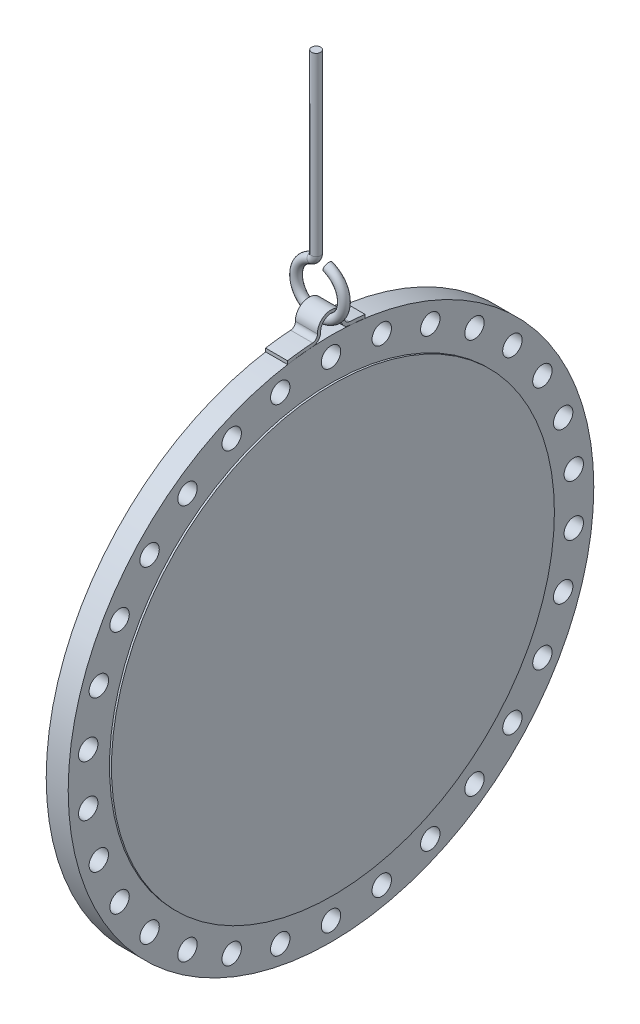
from build123d import *

# Parameters (mm, degrees)
CUT_EXTRUDE1_START  = -37
SKETCH2_R           = 15
CUT_EXTRUDE1_DEPTH  = 34
BOSS_EXTRUDE1_DEPTH = 34
SKETCH5_R           = 7


with BuildPart() as part:
    # Sketch1 → Revolve1 (revolve)
    with BuildSketch(Plane.XY):
        Polygon((0, 0), (-37, 0), (-37, 406.4), (-3, 406.4), (-3, 342.5), (0, 342.5), align=None)
    revolve(axis=Axis((0, 0, 0), (-1, 0, 0)))

    # Sketch2 → Cut-Extrude1 (cut)
    with BuildSketch(Plane(origin=(0, 0, 0), x_dir=(0, 0, -1), z_dir=(1, 0, 0)).offset(CUT_EXTRUDE1_START)):
        with Locations((0, 377.5)):
            Circle(SKETCH2_R)
        with Locations((78.486663284, 369.250719277)):
            Circle(SKETCH2_R)
        with Locations((153.543082761, 344.86341026)):
            Circle(SKETCH2_R)
        with Locations((221.88893274, 305.403915377)):
            Circle(SKETCH2_R)
        with Locations((280.537171618, 252.5968039)):
            Circle(SKETCH2_R)
        with Locations((326.924589929, 188.75)):
            Circle(SKETCH2_R)
        with Locations((359.023834901, 116.653915377)):
            Circle(SKETCH2_R)
        with Locations((375.432015502, 39.459494884)):
            Circle(SKETCH2_R)
        with Locations((375.432015502, -39.459494884)):
            Circle(SKETCH2_R)
        with Locations((359.023834901, -116.653915377)):
            Circle(SKETCH2_R)
        with Locations((326.924589929, -188.75)):
            Circle(SKETCH2_R)
        with Locations((280.537171618, -252.5968039)):
            Circle(SKETCH2_R)
        with Locations((221.88893274, -305.403915377)):
            Circle(SKETCH2_R)
        with Locations((153.543082761, -344.86341026)):
            Circle(SKETCH2_R)
        with Locations((78.486663284, -369.250719277)):
            Circle(SKETCH2_R)
        with Locations((0, -377.5)):
            Circle(SKETCH2_R)
        with Locations((-78.486663284, -369.250719277)):
            Circle(SKETCH2_R)
        with Locations((-153.543082761, -344.86341026)):
            Circle(SKETCH2_R)
        with Locations((-221.88893274, -305.403915377)):
            Circle(SKETCH2_R)
        with Locations((-280.537171618, -252.5968039)):
            Circle(SKETCH2_R)
        with Locations((-326.924589929, -188.75)):
            Circle(SKETCH2_R)
        with Locations((-359.023834901, -116.653915377)):
            Circle(SKETCH2_R)
        with Locations((-375.432015502, -39.459494884)):
            Circle(SKETCH2_R)
        with Locations((-375.432015502, 39.459494884)):
            Circle(SKETCH2_R)
        with Locations((-359.023834901, 116.653915377)):
            Circle(SKETCH2_R)
        with Locations((-326.924589929, 188.75)):
            Circle(SKETCH2_R)
        with Locations((-280.537171618, 252.5968039)):
            Circle(SKETCH2_R)
        with Locations((-221.88893274, 305.403915377)):
            Circle(SKETCH2_R)
        with Locations((-153.543082761, 344.86341026)):
            Circle(SKETCH2_R)
        with Locations((-78.486663284, 369.250719277)):
            Circle(SKETCH2_R)
    extrude(amount=CUT_EXTRUDE1_DEPTH, mode=Mode.SUBTRACT)


with BuildPart() as body_2:
    # Sketch3 → Boss-Extrude1 (new body)
    with BuildSketch(Plane.ZY.offset(37)):
        with BuildLine():
            Line((-52.831200216, 402.951391962), (-52.831200216, 407.993657161))
            ThreePointArc((-52.831200216, 407.993657161), (-40.641928644, 409.387583637), (-28.416512433, 410.417423876))
            ThreePointArc((-28.416512433, 410.417423876), (-23.034874319, 413.039037829), (-20.987102628, 418.664117349))
            ThreePointArc((-20.987102628, 418.664117349), (0, 440.4), (20.987102628, 418.664117349))
            ThreePointArc((20.987102628, 418.664117349), (23.034874319, 413.039037829), (28.416512433, 410.417423876))
            ThreePointArc((28.416512433, 410.417423876), (47.84648121, 408.608216065), (67.168799784, 405.879677165))
            Line((67.168799784, 405.879677165), (67.168799784, 400.810818636))
            ThreePointArc((67.168799784, 400.810818636), (47.675934182, 403.593812267), (28.071148888, 405.429365735))
            ThreePointArc((28.071148888, 405.429365735), (19.320058333, 409.692376479), (15.990173431, 418.839327504))
            ThreePointArc((15.990173431, 418.839327504), (0, 435.4), (-15.990173431, 418.839327504))
            ThreePointArc((-15.990173431, 418.839327504), (-19.320058333, 409.692376479), (-28.071148888, 405.429365735))
            ThreePointArc((-28.071148888, 405.429365735), (-40.470144689, 404.379929508), (-52.831200216, 402.951391962))
        make_face()
    extrude(amount=-BOSS_EXTRUDE1_DEPTH)

    # Sweep1: sweep along a path in Sketch4
    with BuildLine(Plane.XY) as sweep1_path:
        Line((-26, 777.360272527), (-26, 505.042759588))
        ThreePointArc((-26, 505.042759588), (-27.813347656, 499.30004913), (-32.595744681, 495.640044782))
        ThreePointArc((-32.595744681, 495.640044782), (-19.468397742, 423.853819129), (-8.409053262, 495.987586054))
    # Sketch5 → Sweep1 (sweep)
    with BuildSketch(Plane(origin=(0, 777.360272527, 0), x_dir=(1, 0, 0), z_dir=(0, 1, 0))):
        with Locations((-26.018707551, 0)):
            Circle(SKETCH5_R)
    sweep(path=sweep1_path.line)


solid = Compound([part.part, body_2.part])
